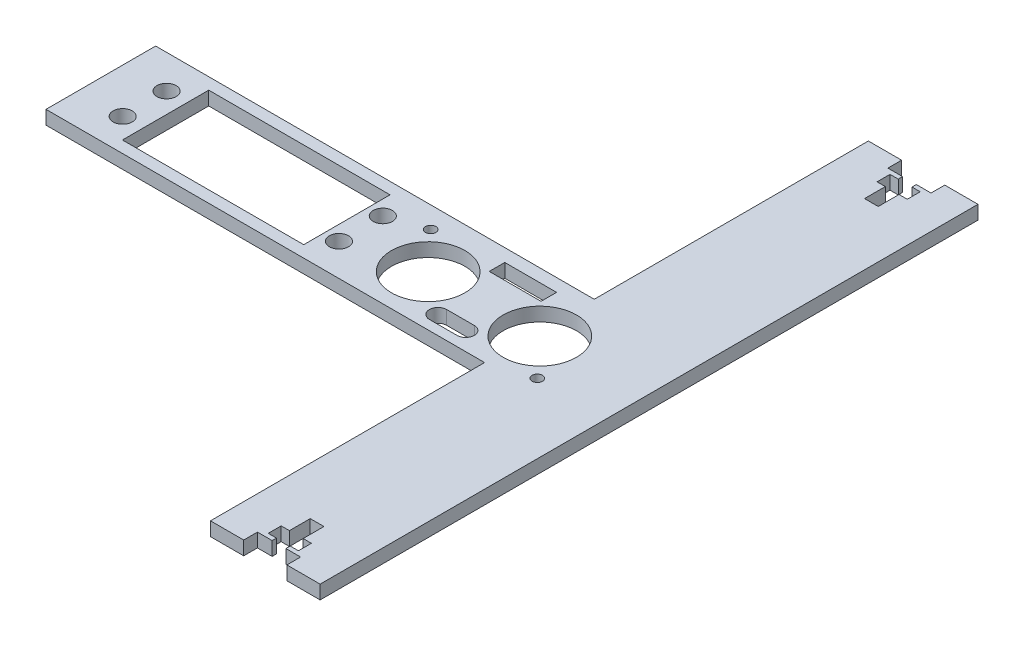
from build123d import *

# Parameters (mm, degrees)
BOSS_EXTRUDE1_DEPTH = 3.18
CUT_EXTRUDE1_DEPTH  = 3.18
SKETCH3_W           = 42
SKETCH3_H           = 20
CUT_EXTRUDE2_DEPTH  = 10
SKETCH4_R           = 2.2225
CUT_EXTRUDE3_DEPTH  = 10
SKETCH5_R           = 8.5
SKETCH5_W           = 12
SKETCH5_H           = 3.600941215
CUT_EXTRUDE4_DEPTH  = 10
SKETCH6_R           = 1.2
CUT_EXTRUDE5_DEPTH  = 10


with BuildPart() as part:
    # Sketch1 → Boss-Extrude1 (new body)
    with BuildSketch(Plane(origin=(0, 0, 0), x_dir=(1, 0, 0), z_dir=(0, 1, 0))):
        Polygon((12.7, 76.2), (-12.7, 76.2), (-12.7, 12.7), (-114.3, 12.7), (-114.3, -12.7), (-12.7, -12.7), (-12.7, -76.2), (12.7, -76.2), align=None)
    extrude(amount=BOSS_EXTRUDE1_DEPTH)

    # Sketch2 → Cut-Extrude1 (cut)
    with BuildSketch(Plane(origin=(0, 3.18, 0), x_dir=(1, 0, 0), z_dir=(0, 1, 0))):
        Polygon((-1.59, 73.02), (-1.59, 72.02), (-3.5, 72.02), (-3.5, 69.02), (-1.59, 69.02), (-1.59, 64.2), (1.59, 64.2), (1.59, 69.02), (3.5, 69.02), (3.5, 72.02), (1.59, 72.02), (1.59, 73.02), (5, 73.02), (5, 76.2), (-5, 76.2), (-5, 73.02), align=None)
        Polygon((1.59, -72.02), (3.5, -72.02), (3.5, -69.02), (1.59, -69.02), (1.59, -64.2), (-1.59, -64.2), (-1.59, -69.02), (-3.5, -69.02), (-3.5, -72.02), (-1.59, -72.02), (-1.59, -73.02), (-5, -73.02), (-5, -76.2), (5, -76.2), (5, -73.02), (1.59, -73.02), align=None)
    extrude(amount=-CUT_EXTRUDE1_DEPTH, mode=Mode.SUBTRACT)

    # Sketch3 → Cut-Extrude2 (cut)
    with BuildSketch(Plane(origin=(0, 0, 0), x_dir=(-1, 0, 0), z_dir=(0, -1, 0))):
        with Locations((78.3, 0)):
            Rectangle(SKETCH3_W, SKETCH3_H)
    extrude(amount=-CUT_EXTRUDE2_DEPTH, mode=Mode.SUBTRACT)

    # Sketch4 → Cut-Extrude3 (cut)
    with BuildSketch(Plane(origin=(0, 0, 0), x_dir=(-1, 0, 0), z_dir=(0, -1, 0))):
        with Locations((103.999, -5.2375)):
            Circle(SKETCH4_R)
        with Locations((103.999, 4.9225)):
            Circle(SKETCH4_R)
        with Locations((53.901, 4.9225)):
            Circle(SKETCH4_R)
        with Locations((53.901, -5.2375)):
            Circle(SKETCH4_R)
    extrude(amount=-CUT_EXTRUDE3_DEPTH, mode=Mode.SUBTRACT)

    # Sketch5 → Cut-Extrude4 (cut)
    with BuildSketch(Plane.XZ):
        with Locations((-37.467456586, 0.996077317)):
            Circle(SKETCH5_R)
        with Locations((-11.607456586, 0.996077317)):
            Circle(SKETCH5_R)
        with BuildLine():
            Line((-27.73362836, 10.446077317), (-21.33362836, 10.446077317))
            ThreePointArc((-21.33362836, 10.446077317), (-19.33362836, 8.446077317), (-21.33362836, 6.446077317))
            Line((-21.33362836, 6.446077317), (-27.73362836, 6.446077317))
            ThreePointArc((-27.73362836, 6.446077317), (-29.73362836, 8.446077317), (-27.73362836, 10.446077317))
        make_face()
        with Locations((-24.446347452, -7.921372698)):
            Rectangle(SKETCH5_W, SKETCH5_H)
    extrude(amount=-CUT_EXTRUDE4_DEPTH, mode=Mode.SUBTRACT)

    # Sketch6 → Cut-Extrude5 (cut)
    with BuildSketch(Plane(origin=(0, 3.18, 0), x_dir=(1, 0, 0), z_dir=(0, 1, 0))):
        with Locations((-3.437456586, -9.746077317)):
            Circle(SKETCH6_R)
        with Locations((-45.637456586, 7.753922683)):
            Circle(SKETCH6_R)
    extrude(amount=-CUT_EXTRUDE5_DEPTH, mode=Mode.SUBTRACT)


solid = part.part
